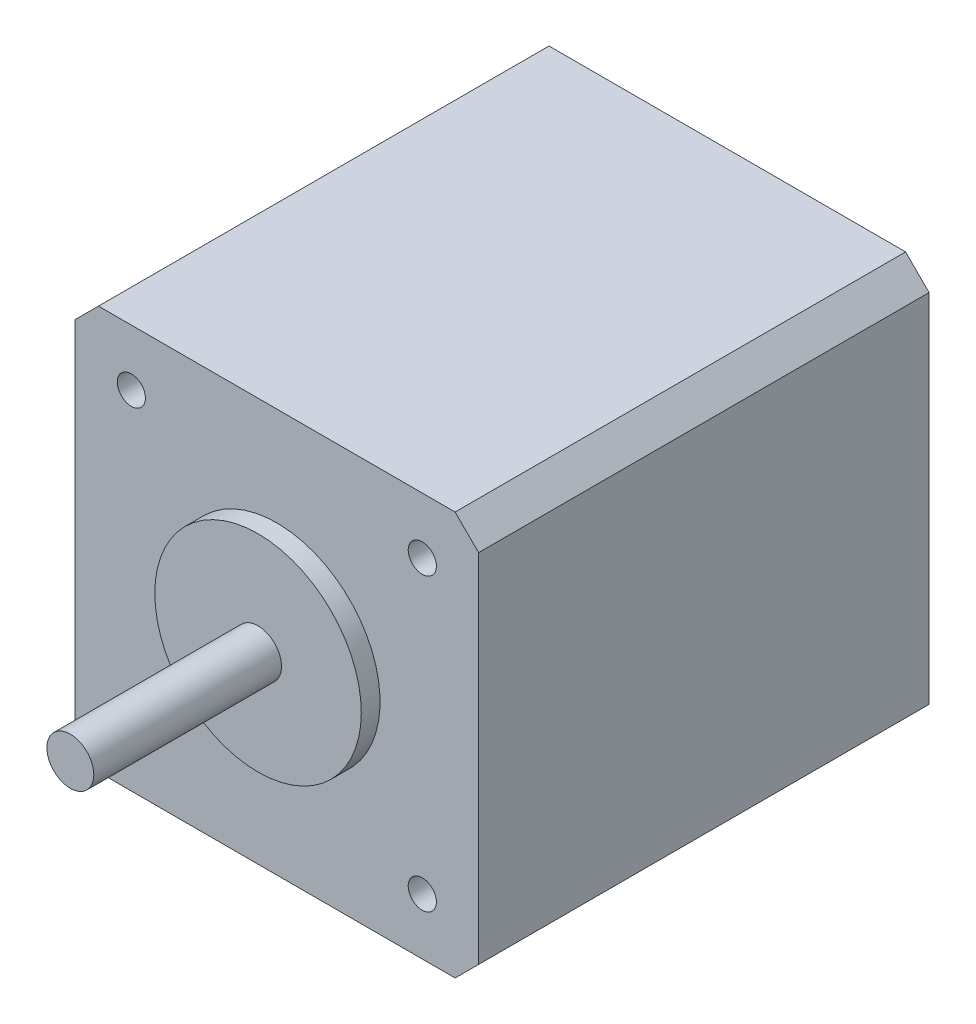
from build123d import *

# Parameters (mm, degrees)
SKETCH1_W           = 43
SKETCH1_H           = 43
BOSS_EXTRUDE1_DEPTH = 48
CHAMFER1_SIZE       = 2.5
SKETCH2_R           = 11
BOSS_EXTRUDE2_DEPTH = 2
SKETCH3_R           = 2.5
BOSS_EXTRUDE3_DEPTH = 20
SKETCH4_R           = 1.5
CUT_EXTRUDE1_DEPTH  = 10


with BuildPart() as part:
    # Sketch1 → Boss-Extrude1 (new body)
    with BuildSketch(Plane.XY):
        Rectangle(SKETCH1_W, SKETCH1_H)
    extrude(amount=BOSS_EXTRUDE1_DEPTH)

    # Chamfer1
    chamfer1_edges = [part.edges().sort_by_distance(p)[0] for p in [
        (21.5, -21.5, 24),
        (-21.5, -21.5, 24),
        (-21.5, 21.5, 24),
        (21.5, 21.5, 24),
    ]]
    chamfer(chamfer1_edges, length=CHAMFER1_SIZE)

    # Sketch2 → Boss-Extrude2 (add)
    with BuildSketch(Plane.XY.offset(48)):
        Circle(SKETCH2_R)
    extrude(amount=BOSS_EXTRUDE2_DEPTH)

    # Sketch3 → Boss-Extrude3 (add)
    with BuildSketch(Plane.XY.offset(50)):
        Circle(SKETCH3_R)
    extrude(amount=BOSS_EXTRUDE3_DEPTH)

    # Sketch4 → Cut-Extrude1 (cut)
    with BuildSketch(Plane.XY.offset(48)):
        with Locations((-15.5, 15.5)):
            Circle(SKETCH4_R)
        with Locations((15.5, 15.5)):
            Circle(SKETCH4_R)
        with Locations((15.5, -15.5)):
            Circle(SKETCH4_R)
        with Locations((-15.5, -15.5)):
            Circle(SKETCH4_R)
    extrude(amount=-CUT_EXTRUDE1_DEPTH, mode=Mode.SUBTRACT)


solid = part.part
